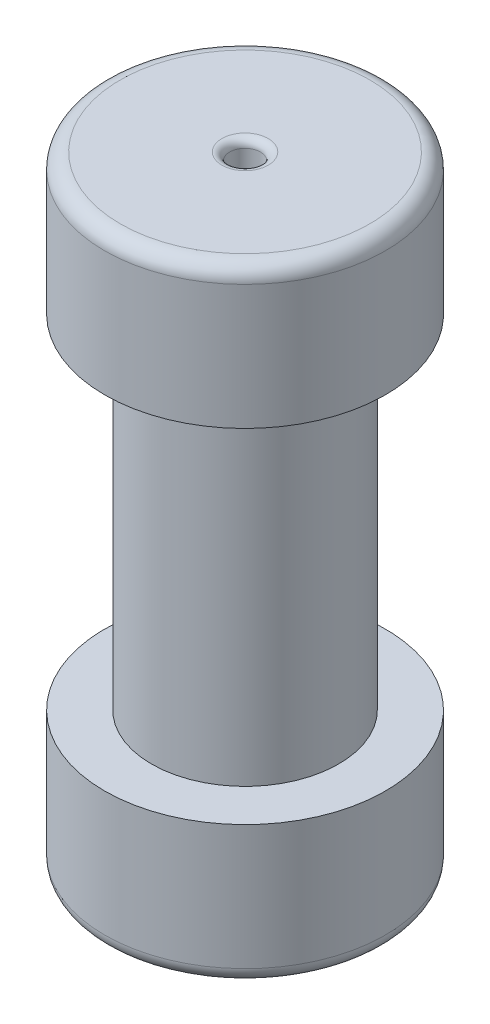
from build123d import *

# Parameters (mm, degrees)
SKETCH1_R           = 22.86
BOSS_EXTRUDE1_DEPTH = 22.86
SKETCH3_R           = 15.24
BOSS_EXTRUDE2_DEPTH = 55.88
SKETCH4_R           = 22.86
BOSS_EXTRUDE3_DEPTH = 22.86
FILLET3_R           = 2.54
SKETCH5_R           = 2.5
CUT_EXTRUDE1_DEPTH  = 7
FILLET4_R           = 1.27
SKETCH8_R           = 3.175
BOSS_EXTRUDE4_DEPTH = 12.7


with BuildPart() as part:
    # Sketch1 → Boss-Extrude1 (new body)
    with BuildSketch(Plane(origin=(0, 0, 0), x_dir=(1, 0, 0), z_dir=(0, 1, 0))):
        Circle(SKETCH1_R)
    extrude(amount=BOSS_EXTRUDE1_DEPTH)

    # Sketch3 → Boss-Extrude2 (add)
    with BuildSketch(Plane(origin=(0, 22.86, 0), x_dir=(1, 0, 0), z_dir=(0, 1, 0))):
        Circle(SKETCH3_R)
    extrude(amount=BOSS_EXTRUDE2_DEPTH)

    # Sketch4 → Boss-Extrude3 (add)
    with BuildSketch(Plane(origin=(0, 78.74, 0), x_dir=(1, 0, 0), z_dir=(0, 1, 0))):
        Circle(SKETCH4_R)
    extrude(amount=BOSS_EXTRUDE3_DEPTH)

    # Fillet3
    fillet3_edges = [part.edges().sort_by_distance(p)[0] for p in [
        (-22.86, 101.6, 0),
        (-22.86, 0, 0),
    ]]
    fillet(fillet3_edges, radius=FILLET3_R)

    # Sketch5 → Cut-Extrude1 (cut)
    with BuildSketch(Plane(origin=(0, 101.6, 0), x_dir=(1, 0, 0), z_dir=(0, 1, 0))):
        Circle(SKETCH5_R)
    extrude(amount=-CUT_EXTRUDE1_DEPTH, mode=Mode.SUBTRACT)

    # Fillet4
    fillet4_edges = [part.edges().sort_by_distance(p)[0] for p in [
        (-2.5, 101.6, 0),
    ]]
    fillet(fillet4_edges, radius=FILLET4_R)

    # Sketch8 → Boss-Extrude4 (add)
    with BuildSketch(Plane.XZ):
        Circle(SKETCH8_R)
    extrude(amount=BOSS_EXTRUDE4_DEPTH)


solid = part.part
